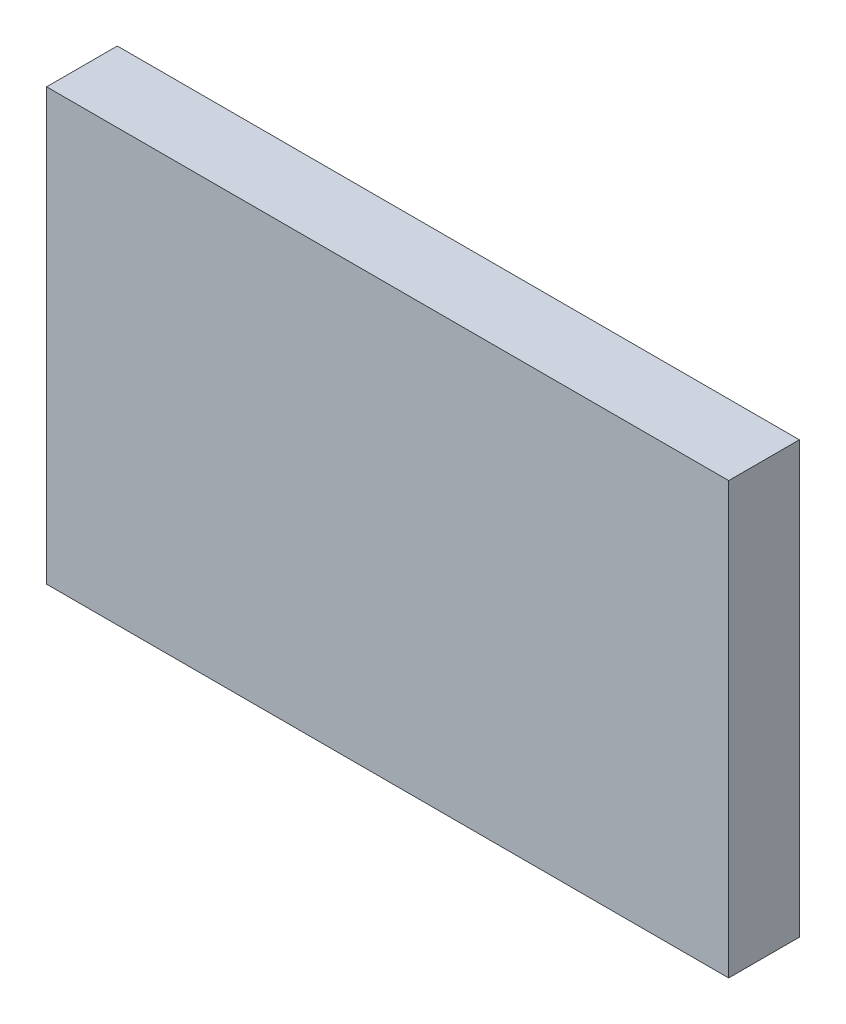
from build123d import *

# Parameters (mm, degrees)
SKETCH1_W               = 9.652
SKETCH1_H               = 6.096
COMPONENT_OUTLINE_DEPTH = 1


with BuildPart() as part:
    # Sketch1 → Component_Outline (new body)
    with BuildSketch(Plane.XY):
        Rectangle(SKETCH1_W, SKETCH1_H)
    extrude(amount=COMPONENT_OUTLINE_DEPTH)


solid = part.part
